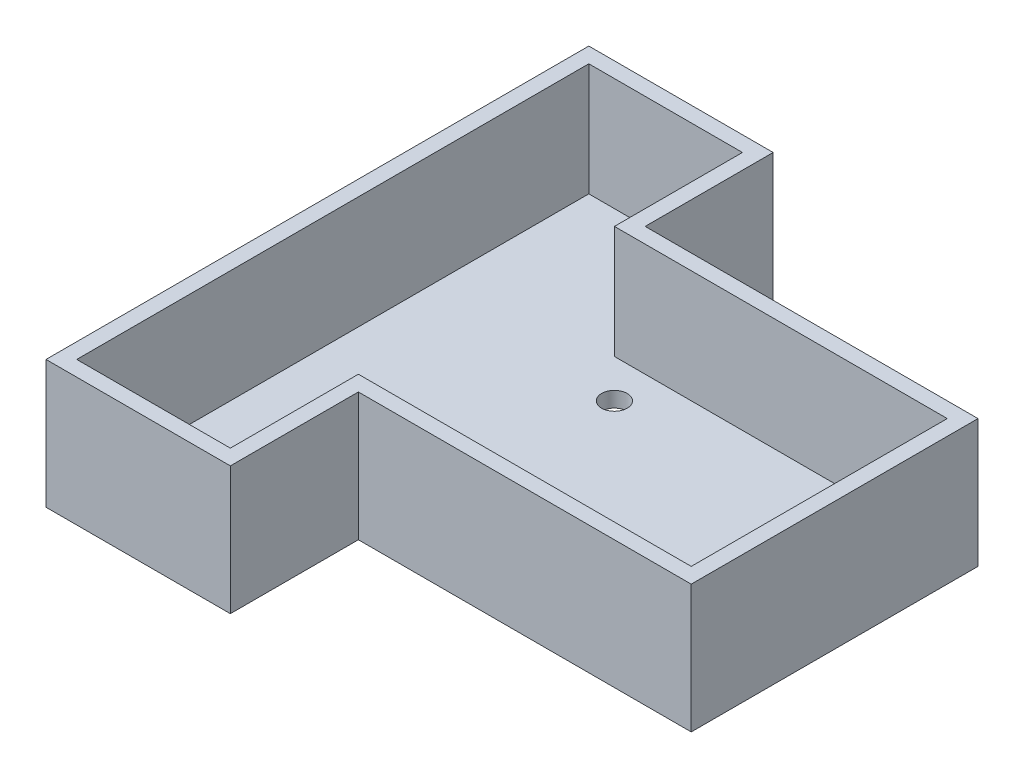
from build123d import *

# Parameters (mm, degrees)
SKETCH1_R           = 2.5
BOSS_EXTRUDE1_DEPTH = 25
CUT_EXTRUDE2_DEPTH  = 22


with BuildPart() as part:
    # Sketch1 → Boss-Extrude1 (new body)
    with BuildSketch(Plane(origin=(0, 0, 0), x_dir=(1, 0, 0), z_dir=(0, 1, 0))):
        Polygon((-29.5, 28), (35.5, 28), (35.5, -28), (-29.5, -28), (-29.5, -53), (-65.5, -53), (-65.5, 53), (-29.5, 53), align=None)
        with Locations((-25, 17.5)):
            Circle(SKETCH1_R, mode=Mode.SUBTRACT)
        with Locations((25, 17.5)):
            Circle(SKETCH1_R, mode=Mode.SUBTRACT)
        with Locations((25, -17.5)):
            Circle(SKETCH1_R, mode=Mode.SUBTRACT)
        with Locations((-25, -17.5)):
            Circle(SKETCH1_R, mode=Mode.SUBTRACT)
    extrude(amount=BOSS_EXTRUDE1_DEPTH)

    # Sketch6 → Cut-Extrude2 (cut)
    with BuildSketch(Plane(origin=(0, 25, 0), x_dir=(1, 0, 0), z_dir=(0, 1, 0))):
        Polygon((-32.5, 25), (-32.5, 50), (-62.5, 50), (-62.5, -50), (-32.5, -50), (-32.5, -25), (32.5, -25), (32.5, 25), align=None)
    extrude(amount=-CUT_EXTRUDE2_DEPTH, mode=Mode.SUBTRACT)


solid = part.part
